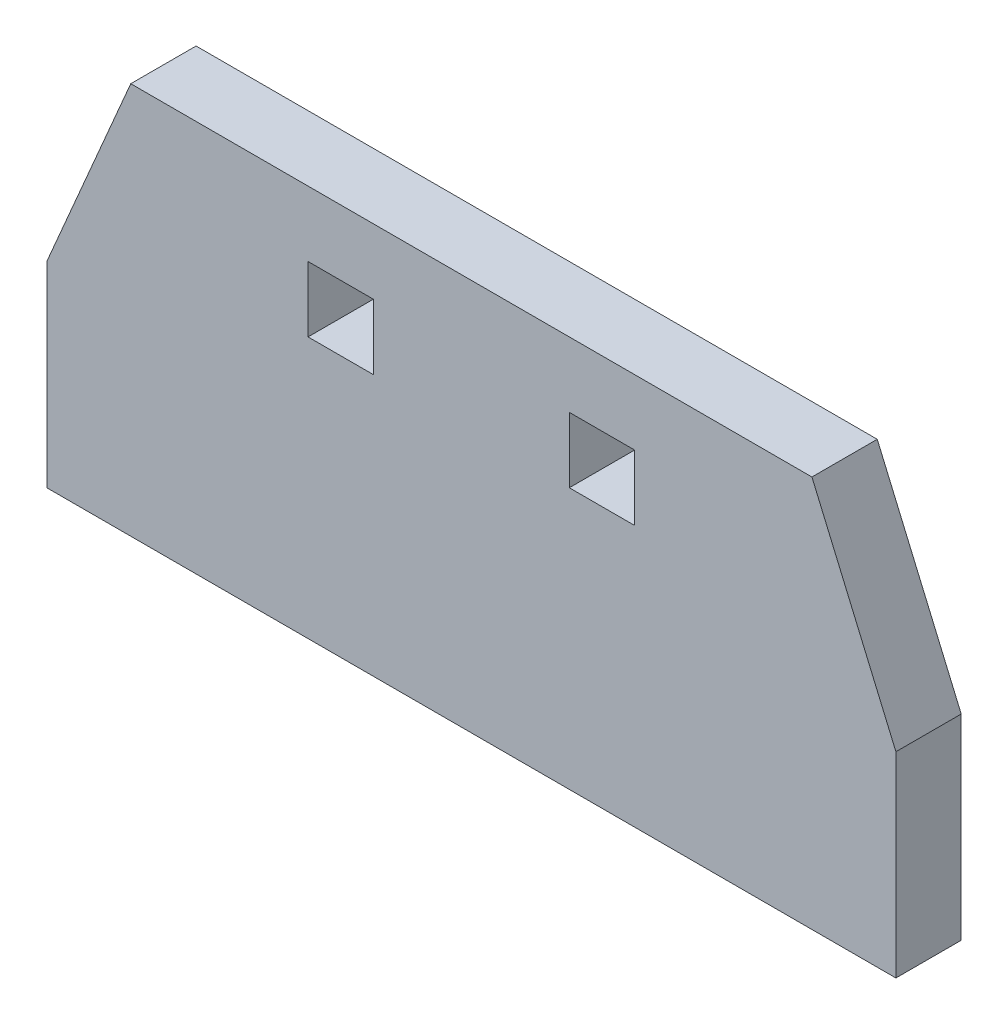
from build123d import *

# Parameters (mm, degrees)
BOSS_EXTRUDE1_DEPTH  = 2
SKETCH2_W            = 5
SKETCH2_H            = 25
SKETCH2_W_2          = 20
BOSS_EXTRUDE2_DEPTH  = 20
SKETCH3_W            = 25
SKETCH3_H            = 2
BOSS_EXTRUDE3_DEPTH  = 25
SKETCH4_W            = 25
SKETCH4_H            = 25
BOSS_EXTRUDE4_DEPTH  = 7
BOSS_EXTRUDE5_DEPTH  = 5
SKETCH6_W            = 50
SKETCH6_H            = 25
BOSS_EXTRUDE6_DEPTH  = 5
BOSS_EXTRUDE7_DEPTH  = 30
CUT_EXTRUDE2_DEPTH   = 30
SKETCH10_W           = 5
SKETCH10_H           = 25
CUT_EXTRUDE3_DEPTH   = 20
SKETCH11_W           = 25
SKETCH11_H           = 25
CUT_EXTRUDE4_DEPTH   = 7
SKETCH13_W           = 5
SKETCH13_H           = 25
CUT_EXTRUDE5_DEPTH   = 10
BOSS_EXTRUDE8_REACH  = 12
SKETCH14_W           = 10
SKETCH14_H           = 5
SKETCH15_W           = 2.5
SKETCH15_H           = 25
CUT_EXTRUDE6_DEPTH   = 15
SKETCH16_W           = 5
SKETCH16_H           = 15
CUT_EXTRUDE7_DEPTH   = 26
SKETCH17_W           = 5
SKETCH17_H           = 15
CUT_EXTRUDE8_DEPTH   = 43.5
SKETCH18_W           = 5
SKETCH18_H           = 15
CUT_EXTRUDE9_DEPTH   = 6
CUT_EXTRUDE10_DEPTH  = 43.5
CUT_EXTRUDE11_DEPTH  = 43.5
SKETCH21_W           = 5
SKETCH21_H           = 5
SKETCH21_H_2         = 15
BOSS_EXTRUDE9_DEPTH  = 5
SKETCH22_W           = 5
SKETCH22_H           = 5
SKETCH22_W_2         = 50
SKETCH22_H_2         = 15
CUT_EXTRUDE12_DEPTH  = 6
SKETCH23_W           = 5
SKETCH23_H           = 5
CUT_EXTRUDE13_DEPTH  = 6
BOSS_EXTRUDE10_DEPTH = 15
BOSS_EXTRUDE11_DEPTH = 5
SKETCH26_W           = 65
SKETCH26_H           = 5
CUT_EXTRUDE14_DEPTH  = 20


with BuildPart() as part:
    # Sketch1 → Boss-Extrude1 (new body)
    with BuildSketch(Plane.XY):
        Polygon((-5, 75), (2.5, 25), (2.5, 0), (22.5, 0), (22.5, 25), (30, 75), (30, 100), (25, 100), (25, 75), (0, 75), (0, 100), (-5, 100), align=None)
    extrude(amount=BOSS_EXTRUDE1_DEPTH)

    # Sketch2 → Boss-Extrude2 (add)
    with BuildSketch(Plane(origin=(0, 0, 0), x_dir=(-1, 0, 0), z_dir=(0, 0, -1))):
        with Locations((-27.5, 87.5)):
            Rectangle(SKETCH2_W, SKETCH2_H)
        with Locations((2.5, 87.5)):
            Rectangle(SKETCH2_W, SKETCH2_H)
        with Locations((-12.5, 12.5)):
            Rectangle(SKETCH2_W_2, SKETCH2_H)
    extrude(amount=BOSS_EXTRUDE2_DEPTH)

    # Sketch3 → Boss-Extrude3 (add)
    with BuildSketch(Plane(origin=(0, 75, 0), x_dir=(1, 0, 0), z_dir=(0, 1, 0))):
        with Locations((12.5, -1)):
            Rectangle(SKETCH3_W, SKETCH3_H)
    extrude(amount=BOSS_EXTRUDE3_DEPTH)

    # Sketch4 → Boss-Extrude4 (add)
    with BuildSketch(Plane(origin=(0, 0, 0), x_dir=(-1, 0, 0), z_dir=(0, 0, -1))):
        with Locations((-12.5, 87.5)):
            Rectangle(SKETCH4_W, SKETCH4_H)
    extrude(amount=BOSS_EXTRUDE4_DEPTH)

    # Sketch5 → Boss-Extrude5 (add)
    with BuildSketch(Plane(origin=(0, 0, 0), x_dir=(-1, 0, 0), z_dir=(0, 0, -1))):
        Polygon((5, 75), (5, 0), (-2.5, 0), (-22.5, 0), (-30, 0), (-30, 75), (-30, 100), (5, 100), align=None)
    extrude(amount=-BOSS_EXTRUDE5_DEPTH)

    # Sketch6 → Boss-Extrude6 (add)
    with BuildSketch(Plane.XY.offset(5)):
        with Locations((12.5, 12.5)):
            Rectangle(SKETCH6_W, SKETCH6_H)
    extrude(amount=-BOSS_EXTRUDE6_DEPTH)

    # Sketch8 → Boss-Extrude7 (add)
    with BuildSketch(Plane.XZ.offset(-75)):
        Polygon((-5, 0), (-5, -20), (0, -20), (0, -7), (25, -7), (25, -20), (30, -20), (30, 0), align=None)
    extrude(amount=BOSS_EXTRUDE7_DEPTH)

    # Sketch9 → Cut-Extrude2 (cut)
    with BuildSketch(Plane(origin=(0, 100, 0), x_dir=(1, 0, 0), z_dir=(0, 1, 0))):
        Polygon((30, 20), (25, 20), (25, 7), (0, 7), (0, 20), (-5, 20), (-5, -5), (30, -5), align=None)
    extrude(amount=-CUT_EXTRUDE2_DEPTH, mode=Mode.SUBTRACT)

    # Sketch10 → Cut-Extrude3 (cut)
    with BuildSketch(Plane(origin=(0, 0, -20), x_dir=(-1, 0, 0), z_dir=(0, 0, -1))):
        with Locations((-20, 12.5)):
            Rectangle(SKETCH10_W, SKETCH10_H)
        with Locations((-5, 12.5)):
            Rectangle(SKETCH10_W, SKETCH10_H)
    extrude(amount=-CUT_EXTRUDE3_DEPTH, mode=Mode.SUBTRACT)

    # Sketch11 → Cut-Extrude4 (cut)
    with BuildSketch(Plane(origin=(0, 0, -7), x_dir=(-1, 0, 0), z_dir=(0, 0, -1))):
        with Locations((-12.5, 57.5)):
            Rectangle(SKETCH11_W, SKETCH11_H)
    extrude(amount=-CUT_EXTRUDE4_DEPTH, mode=Mode.SUBTRACT)

    # Sketch13 → Cut-Extrude5 (cut)
    with BuildSketch(Plane(origin=(17.5, 0, 0), x_dir=(0, 0, -1), z_dir=(1, 0, 0))):
        Polygon((5, 25), (5, 20), (10, 20), (10, 5), (0, 5), (0, 25), align=None)
        with Locations((17.5, 12.5)):
            Rectangle(SKETCH13_W, SKETCH13_H)
    extrude(amount=-CUT_EXTRUDE5_DEPTH, mode=Mode.SUBTRACT)

    # Sketch14 → Boss-Extrude8 (add, up to next)
    with BuildSketch(Plane.XY.offset(-5), mode=Mode.PRIVATE) as boss_extrude8_sk1:
        with Locations((12.5, 22.5)):
            Rectangle(SKETCH14_W, SKETCH14_H)
    boss_extrude8_tool1 = extrude(boss_extrude8_sk1.sketch, amount=BOSS_EXTRUDE8_REACH, mode=Mode.PRIVATE) - part.part
    add(boss_extrude8_tool1.solids().sort_by_distance((12.5, 22.5, -5))[0])

    # Sketch15 → Cut-Extrude6 (cut)
    with BuildSketch(Plane(origin=(0, 0, -15), x_dir=(-1, 0, 0), z_dir=(0, 0, -1))):
        with Locations((-8.75, 12.5)):
            Rectangle(SKETCH15_W, SKETCH15_H)
        with Locations((-16.25, 12.5)):
            Rectangle(SKETCH15_W, SKETCH15_H)
    extrude(amount=-CUT_EXTRUDE6_DEPTH, mode=Mode.SUBTRACT)

    # Sketch16 → Cut-Extrude7 (cut, through all)
    with BuildSketch(Plane.XY.offset(5)):
        with Locations((-5, 12.5)):
            Rectangle(SKETCH16_W, SKETCH16_H)
        with Locations((30, 12.5)):
            Rectangle(SKETCH16_W, SKETCH16_H)
    extrude(amount=-CUT_EXTRUDE7_DEPTH, mode=Mode.SUBTRACT)

    # Sketch17 → Cut-Extrude8 (cut, through all)
    with BuildSketch(Plane(origin=(30, 0, 0), x_dir=(0, 0, -1), z_dir=(1, 0, 0))):
        with Locations((2.5, 57.5)):
            Rectangle(SKETCH17_W, SKETCH17_H)
    extrude(amount=-CUT_EXTRUDE8_DEPTH, mode=Mode.SUBTRACT)

    # Sketch18 → Cut-Extrude9 (cut, through all)
    with BuildSketch(Plane(origin=(0, 0, 0), x_dir=(-1, 0, 0), z_dir=(0, 0, -1))):
        with Locations((-2.5, 57.5)):
            Rectangle(SKETCH18_W, SKETCH18_H)
        with Locations((-22.5, 57.5)):
            Rectangle(SKETCH18_W, SKETCH18_H)
    extrude(amount=-CUT_EXTRUDE9_DEPTH, mode=Mode.SUBTRACT)

    # Sketch19 → Cut-Extrude10 (cut, through all)
    with BuildSketch(Plane(origin=(30, 0, 0), x_dir=(0, 0, -1), z_dir=(1, 0, 0))):
        Polygon((5, 60), (10, 60), (10, 45), (20, 45), (20, 70), (-5, 70), (-5, 60), (0, 60), align=None)
    extrude(amount=-CUT_EXTRUDE10_DEPTH, mode=Mode.SUBTRACT)

    # Sketch20 → Cut-Extrude11 (cut, through all)
    with BuildSketch(Plane(origin=(30, 0, 0), x_dir=(0, 0, -1), z_dir=(1, 0, 0))):
        Polygon((10, 45), (15, 25), (15, 0), (0, 0), (0, 60), (10, 60), align=None)
    extrude(amount=-CUT_EXTRUDE11_DEPTH, mode=Mode.SUBTRACT)

    # Sketch21 → Boss-Extrude9 (add)
    with BuildSketch(Plane(origin=(0, 0, 0), x_dir=(-1, 0, 0), z_dir=(0, 0, -1))):
        with Locations((-2.5, 57.5)):
            Rectangle(SKETCH21_W, SKETCH21_H)
        with Locations((-22.5, 57.5)):
            Rectangle(SKETCH21_W, SKETCH21_H)
        with Locations((5, 12.5)):
            Rectangle(SKETCH21_W, SKETCH21_H_2)
        with Locations((-30, 12.5)):
            Rectangle(SKETCH21_W, SKETCH21_H_2)
    extrude(amount=-BOSS_EXTRUDE9_DEPTH)

    # Sketch22 → Cut-Extrude12 (cut, through all)
    with BuildSketch(Plane(origin=(0, 0, 0), x_dir=(-1, 0, 0), z_dir=(0, 0, -1))):
        with Locations((-12.5, 22.5)):
            Rectangle(SKETCH22_W, SKETCH22_H)
        with Locations((-12.5, 7.5)):
            Rectangle(SKETCH22_W_2, SKETCH22_H_2)
    extrude(amount=-CUT_EXTRUDE12_DEPTH, mode=Mode.SUBTRACT)

    # Sketch23 → Cut-Extrude13 (cut, through all)
    with BuildSketch(Plane(origin=(0, 0, 0), x_dir=(-1, 0, 0), z_dir=(0, 0, -1))):
        with Locations((-22.5, 32.5)):
            Rectangle(SKETCH23_W, SKETCH23_H)
        with Locations((-2.5, 32.5)):
            Rectangle(SKETCH23_W, SKETCH23_H)
    extrude(amount=-CUT_EXTRUDE13_DEPTH, mode=Mode.SUBTRACT)

    # Sketch24 → Boss-Extrude10 (add)
    with BuildSketch(Plane.XZ.offset(-25)):
        Polygon((-12.5, 5), (-20, 5), (-20, 0), (-12.5, 0), (37.5, 0), (45, 0), (45, 5), (37.5, 5), align=None)
    extrude(amount=BOSS_EXTRUDE10_DEPTH)

    # Sketch25 → Boss-Extrude11 (add, through all)
    with BuildSketch(Plane.XY.offset(5)):
        Polygon((45, 25), (30, 25), (30, 60), align=None)
        Polygon((-5, 25), (-5, 60), (-20, 25), align=None)
    extrude(amount=-BOSS_EXTRUDE11_DEPTH)

    # Sketch26 → Cut-Extrude14 (cut)
    with BuildSketch(Plane(origin=(0, 60, 0), x_dir=(1, 0, 0), z_dir=(0, 1, 0))):
        with Locations((12.5, -2.5)):
            Rectangle(SKETCH26_W, SKETCH26_H)
    extrude(amount=-CUT_EXTRUDE14_DEPTH, mode=Mode.SUBTRACT)


solid = part.part
